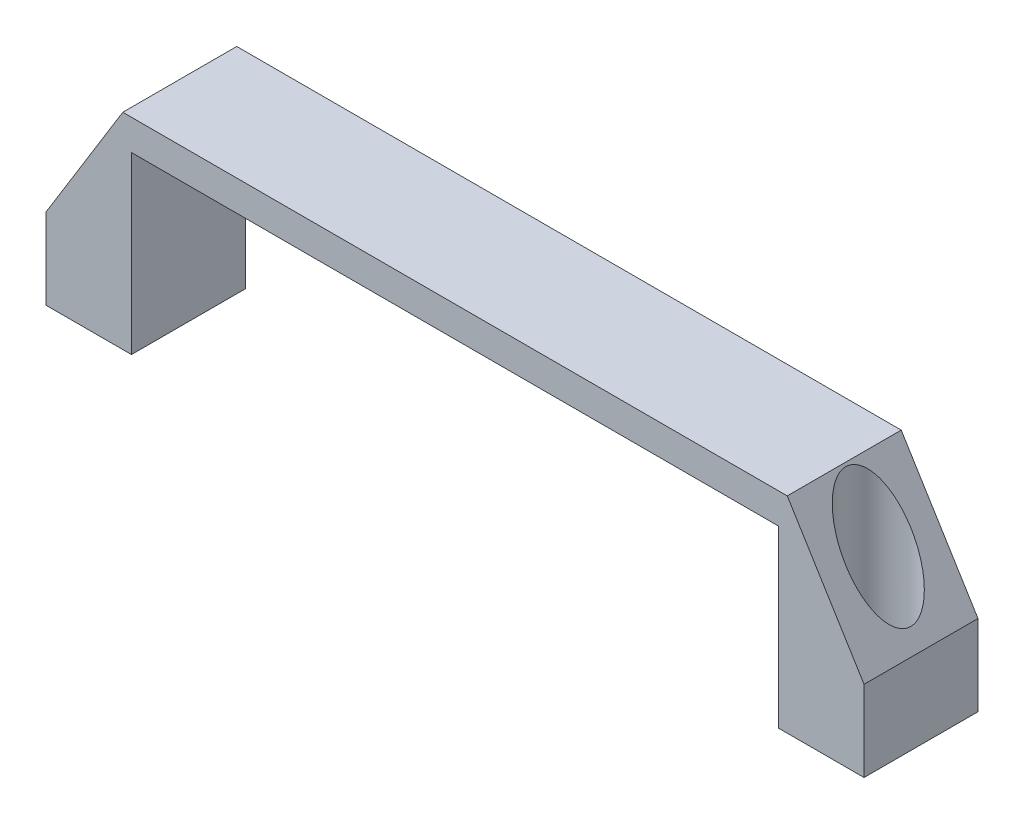
from build123d import *

# Parameters (mm, degrees)
EXTRUDE_1_DEPTH     = 14
SKETCH_3_R          = 4.25
CUT_EXTRUDE_1_DEPTH = 51.5
SKETCH_4_R          = 8
CUT_EXTRUDE_2_DEPTH = 46


with BuildPart() as part:
    # 草图1 → 凸台-拉伸1 (new body, symmetric)
    with BuildSketch(Plane.XY):
        Polygon((-100.5, -42.991652571), (-79.5, -42.991652571), (-79.5, 0.008347429), (79.5, 0.008347429), (79.5, -42.991652571), (100.5, -42.991652571), (100.5, -23.151157314), (81.63217636, 7.508347429), (-81.63217636, 7.508347429), (-100.5, -23.151157314), align=None)
    extrude(amount=EXTRUDE_1_DEPTH, both=True)

    # 草图3 → 切除-拉伸1 (cut, through all)
    with BuildSketch(Plane.XZ.offset(42.991652571)):
        with Locations((-90, 0)):
            Circle(SKETCH_3_R)
        with Locations((90, 0)):
            Circle(SKETCH_3_R)
    extrude(amount=-CUT_EXTRUDE_1_DEPTH, mode=Mode.SUBTRACT)

    # 草图4 → 切除-拉伸2 (cut)
    with BuildSketch(Plane(origin=(0, 7.508347429, 0), x_dir=(1, 0, 0), z_dir=(0, 1, 0))):
        with Locations((-90, 0)):
            Circle(SKETCH_4_R)
        with Locations((90, 0)):
            Circle(SKETCH_4_R)
    extrude(amount=-CUT_EXTRUDE_2_DEPTH, mode=Mode.SUBTRACT)


solid = part.part
